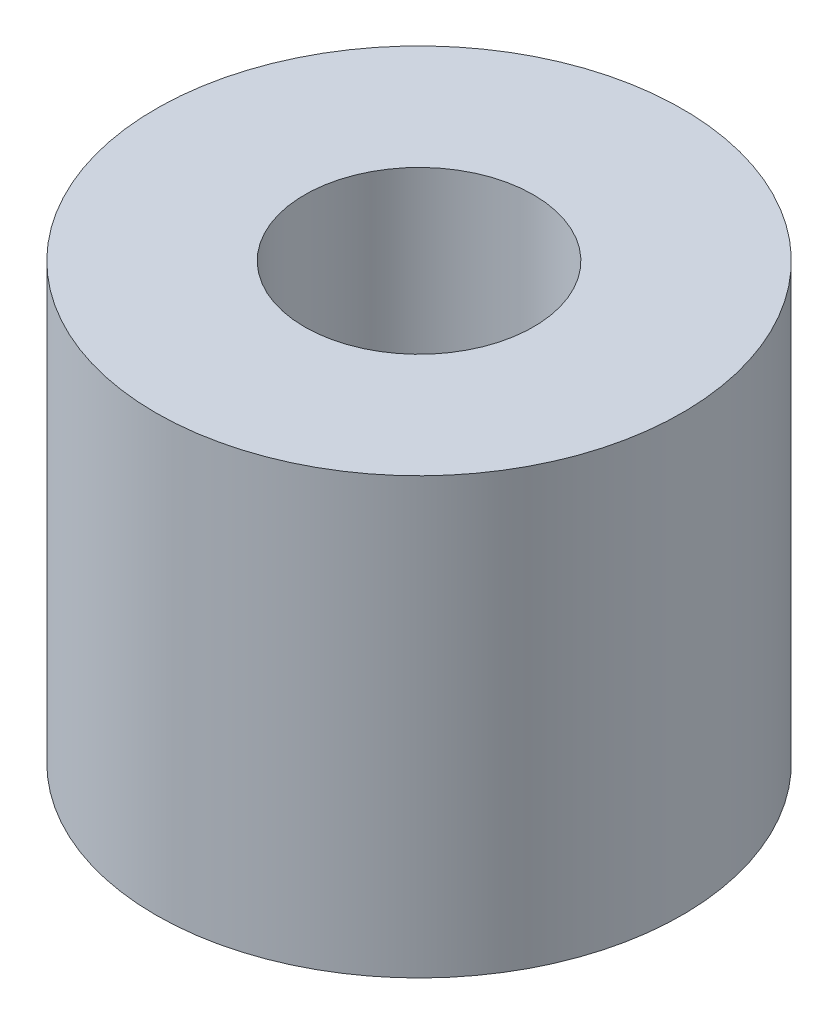
from build123d import *

# Parameters (mm, degrees)
SKETCH1_R           = 11.5
BOSS_EXTRUDE1_DEPTH = 19
SKETCH2_R           = 5
CUT_EXTRUDE1_DEPTH  = 20


with BuildPart() as part:
    # Sketch1 → Boss-Extrude1 (new body)
    with BuildSketch(Plane(origin=(0, 0, 0), x_dir=(1, 0, 0), z_dir=(0, 1, 0))):
        Circle(SKETCH1_R)
    extrude(amount=BOSS_EXTRUDE1_DEPTH)

    # Sketch2 → Cut-Extrude1 (cut, through all)
    with BuildSketch(Plane(origin=(0, 19, 0), x_dir=(1, 0, 0), z_dir=(0, 1, 0))):
        Circle(SKETCH2_R)
    extrude(amount=-CUT_EXTRUDE1_DEPTH, mode=Mode.SUBTRACT)


solid = part.part
